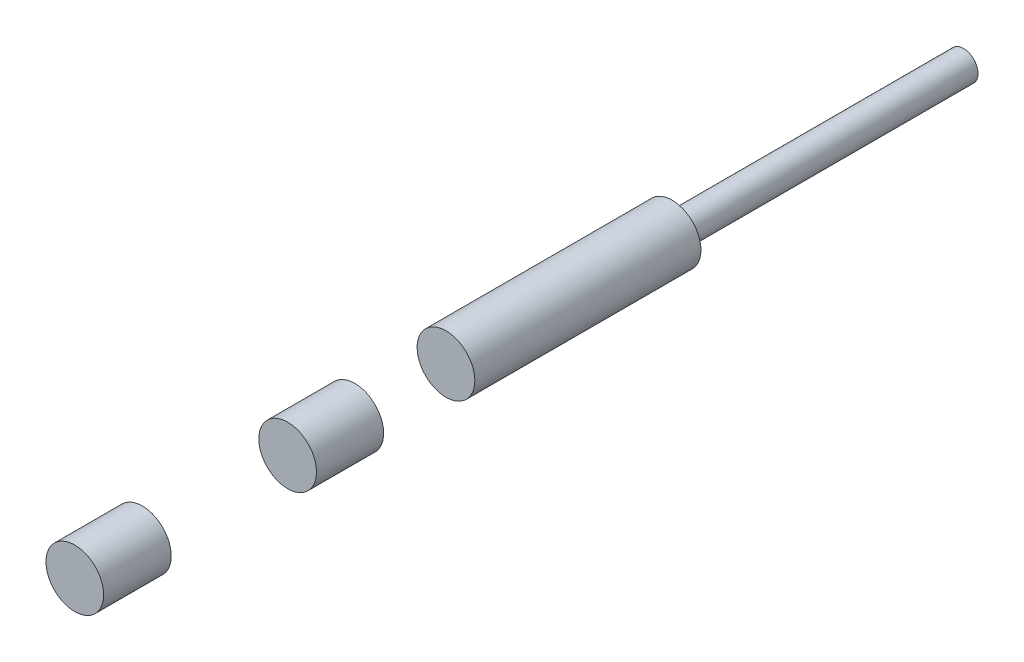
from build123d import *

# Parameters (mm, degrees)
IZIM1_R                          = 9.9
Y_KSEKLIK_EKSTR_ZYON1_DEPTH      = 149
Y_KSEKLIK_EKSTR_ZYON1_DEPTH_BACK = 106
IZIM4_R                          = 9.9
IZIM4_R_2                        = 5
KES_EKSTR_ZYON4_DEPTH            = 50
SKETCH1_R                        = 5
BOSS_EXTRUDE1_DEPTH              = 50
SKETCH2_W                        = 49.865172684
SKETCH2_H                        = 45.050604287
SKETCH2_W_2                      = 31.294694581
SKETCH2_H_2                      = 47.113990743
CUT_EXTRUDE1_DEPTH               = 110


with BuildPart() as part:
    # Çizim1 → Yükseklik-Ekstrüzyon1 (new body, two sides)
    with BuildSketch(Plane.XY) as y_kseklik_ekstr_zyon1_sk:
        Circle(IZIM1_R)
    extrude(amount=Y_KSEKLIK_EKSTR_ZYON1_DEPTH)
    extrude(y_kseklik_ekstr_zyon1_sk.sketch, amount=-Y_KSEKLIK_EKSTR_ZYON1_DEPTH_BACK)

    # Çizim4 → Kes-Ekstrüzyon4 (cut)
    with BuildSketch(Plane(origin=(0, 0, -106), x_dir=(-1, 0, 0), z_dir=(0, 0, -1))):
        Circle(IZIM4_R)
        Circle(IZIM4_R_2, mode=Mode.SUBTRACT)
    extrude(amount=-KES_EKSTR_ZYON4_DEPTH, mode=Mode.SUBTRACT)

    # Sketch1 → Boss-Extrude1 (add)
    with BuildSketch(Plane(origin=(0, 0, -106), x_dir=(-1, 0, 0), z_dir=(0, 0, -1))):
        Circle(SKETCH1_R)
    extrude(amount=BOSS_EXTRUDE1_DEPTH)

    # Sketch2 → Cut-Extrude1 (cut)
    with BuildSketch(Plane(origin=(30, 0, 0), x_dir=(0, 0, -1), z_dir=(1, 0, 0))):
        with Locations((-100.872964895, -1.891437585)):
            Rectangle(SKETCH2_W, SKETCH2_H)
        with Locations((-37.251882505, -2.923130813)):
            Rectangle(SKETCH2_W_2, SKETCH2_H_2)
    extrude(amount=-CUT_EXTRUDE1_DEPTH, mode=Mode.SUBTRACT)


solid = part.part
